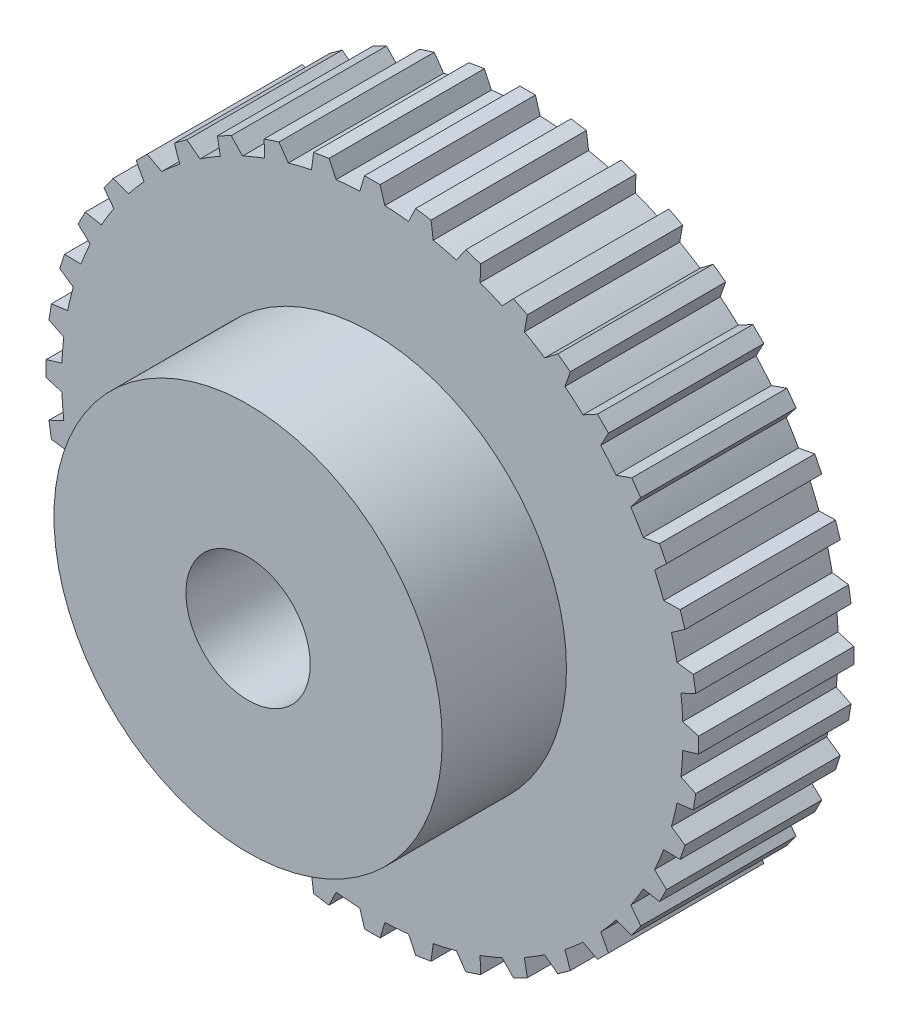
from build123d import *

# Parameters (mm, degrees)
SKETCH_1_R               = 20
EXTRUDE_1_DEPTH          = 10
SKETCH_2_R               = 12.5
EXTRUDE_2_DEPTH          = 8
SKETCH_3_R               = 4
CUT_EXTRUDE_1_DEPTH      = 19
EXTRUDE_3_DEPTH          = 10
PATTERN_CIRCULAR_1_COUNT = 40


with BuildPart() as part:
    # 草圖1 → 填料-伸長1 (new body)
    with BuildSketch(Plane.XY):
        Circle(SKETCH_1_R)
    extrude(amount=EXTRUDE_1_DEPTH)

    # 草圖2 → 填料-伸長2 (add)
    with BuildSketch(Plane.XY.offset(10)):
        Circle(SKETCH_2_R)
    extrude(amount=EXTRUDE_2_DEPTH)

    # 草圖3 → 除料-伸長1 (cut, through all)
    with BuildSketch(Plane.XY.offset(18)):
        Circle(SKETCH_3_R)
    extrude(amount=-CUT_EXTRUDE_1_DEPTH, mode=Mode.SUBTRACT)

    # 草圖4 → 填料-伸長3 (add)
    with BuildSketch(Plane(origin=(0, 0, 0), x_dir=(-1, 0, 0), z_dir=(0, 0, -1))):
        Polygon((-0.5, 21), (0.5, 21), (2, 16), (-2, 16), align=None)
    extrude_3 = extrude(amount=-EXTRUDE_3_DEPTH)

    # 環狀複製排列1: 填料-伸長3 ×40 about axis
    pattern_circular_1_axis = Axis((0, 0, 0), (0, 0, 1))
    for i in range(1, PATTERN_CIRCULAR_1_COUNT):
        add(extrude_3.rotate(pattern_circular_1_axis, i * 360 / PATTERN_CIRCULAR_1_COUNT))


solid = part.part
